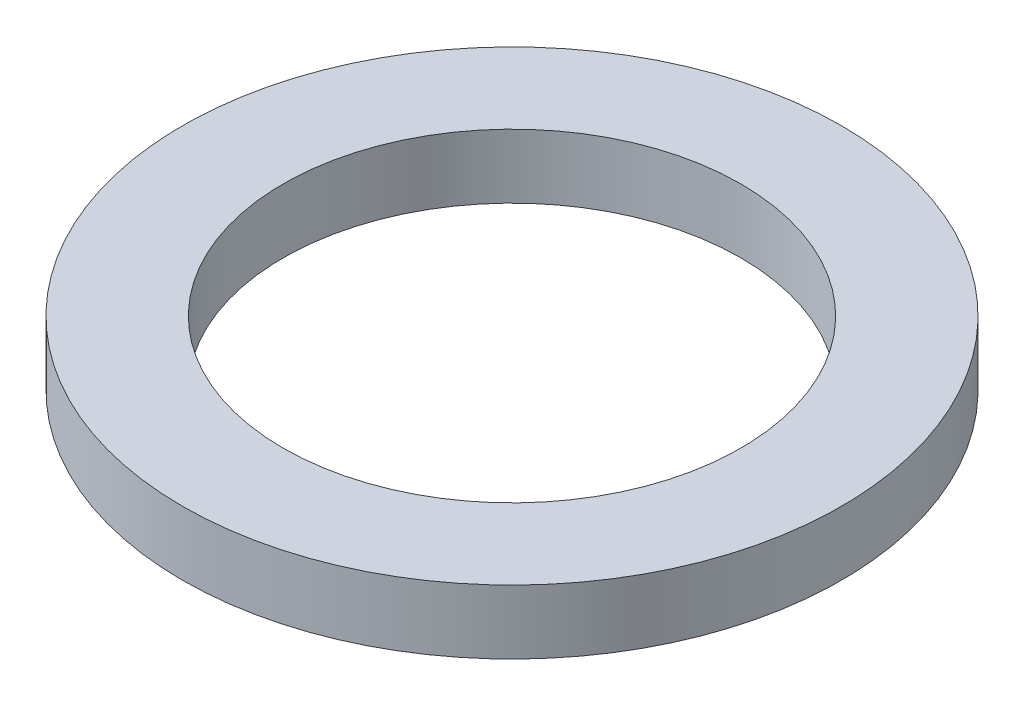
from build123d import *

# Parameters (mm, degrees)
ESQUISSE1_W = 5.5
ESQUISSE1_H = 3.5


with BuildPart() as part:
    # Esquisse1 → Base-Révolution (revolve)
    with BuildSketch(Plane.XY):
        with Locations((15.25, 1.75)):
            Rectangle(ESQUISSE1_W, ESQUISSE1_H)
    revolve(axis=Axis((0, 60, 0), (0, -1, 0)))


solid = part.part
